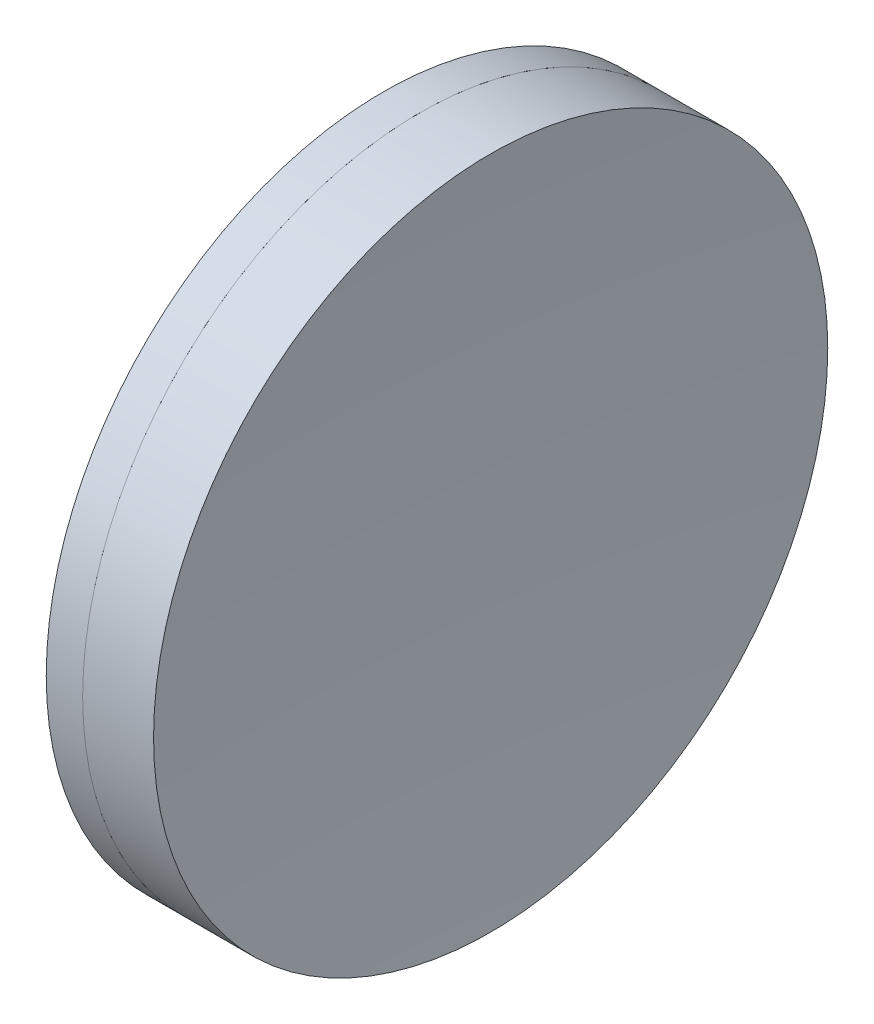
from build123d import *


with BuildPart() as part:
    # 草图1 one side → 旋转1 (revolve)
    with BuildSketch(Plane(origin=(0, 0, 0), x_dir=(1, 0, 0), z_dir=(0, 1, 0)), mode=Mode.PRIVATE) as revolve_1_sk:
        with BuildLine():
            ThreePointArc((316.452902095, 25.4), (315.047287575, 12.734555664), (314.577900269, 0))
            Line((314.577900269, 0), (320.577900269, 0))
            ThreePointArc((320.577900269, 0), (320.232388277, 12.7187582), (319.196871455, 25.4))
            Line((319.196871455, 25.4), (316.452902095, 25.4))
        make_face()
    revolve(revolve_1_sk.sketch.rotate(Axis((-0.816062176, 0, 0), (1, 0, 0)), 180), axis=Axis((-0.816062176, 0, 0), (1, 0, 0)))  # turned: the seam where the file's is


with BuildPart() as body_2:
    # 草图2 one side → 旋转2 (revolve)
    with BuildSketch(Plane(origin=(0, 0, 0), x_dir=(1, 0, 0), z_dir=(0, 1, 0))):
        with BuildLine():
            Line((324.539335324, 25.4), (319.196871455, 25.4))
            ThreePointArc((319.196871455, 25.4), (320.232388277, 12.7187582), (320.577900269, 0))
            Line((320.577900269, 0), (323.577900269, 0))
            ThreePointArc((323.577900269, 0), (323.818345065, 12.709094749), (324.539335324, 25.4))
        make_face()
    revolve(axis=Axis((-0.551919993, 0, 0), (1, 0, 0)))


solid = Compound([part.part, body_2.part])
